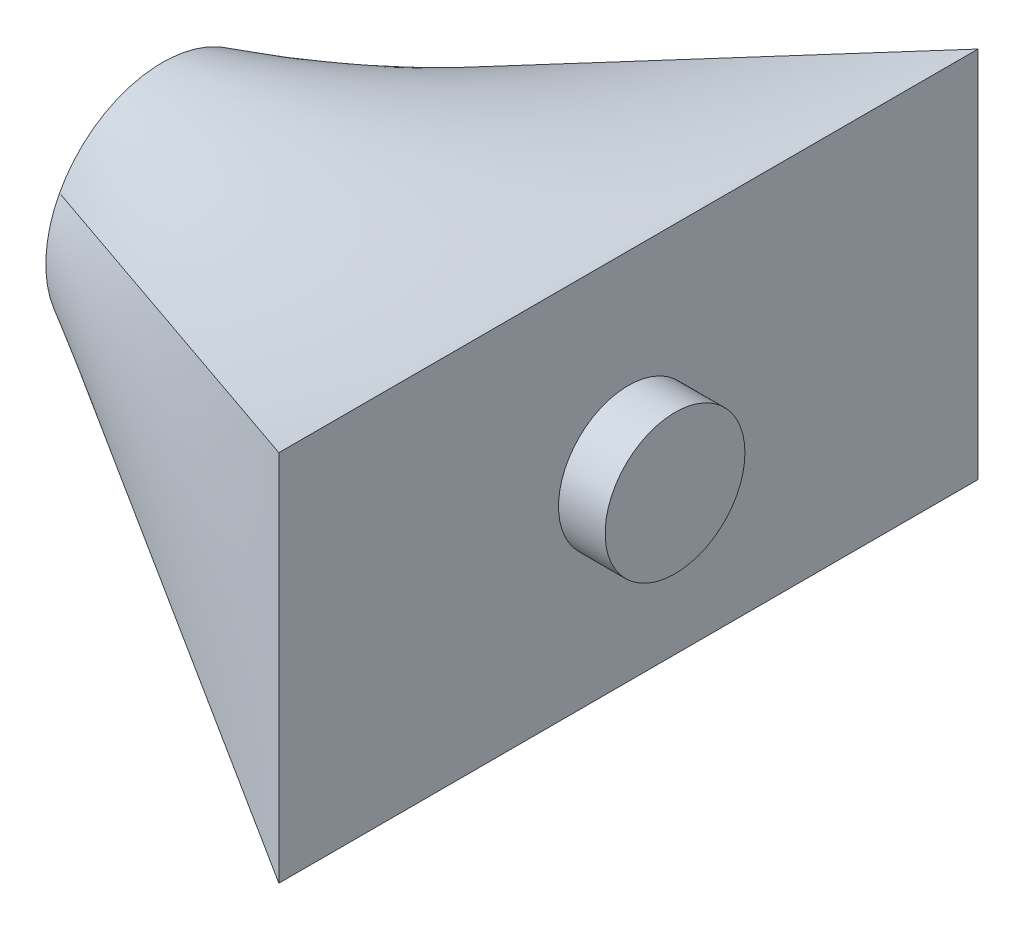
from build123d import *

# Parameters (mm, degrees)
SKETCH2_W           = 150
SKETCH2_H           = 80
SKETCH3_R           = 15
BOSS_EXTRUDE1_DEPTH = 10


with BuildPart() as part:
    # Sketch2 → Loft1 section 0
    with BuildSketch(Plane(origin=(100, 0, 0), x_dir=(0, 0, -1), z_dir=(1, 0, 0))):
        Rectangle(SKETCH2_W, SKETCH2_H)
    # Sketch1 for Loft1 → Loft1 section 1
    with BuildSketch(Plane(origin=(0, 0, 0), x_dir=(0, 0, -1), z_dir=(1, 0, 0))):
        with BuildLine():
            # circular arc as an exact rational Bezier (weights 1, cos(half-angle), 1)
            Bezier((-22.058823529, 11.764705882), (0, 53.125000003), (22.058823529, 11.764705882), weights=[1, 0.470588235, 1])
            Bezier((22.058823529, 11.764705882), (28.333333334, 0), (22.058823529, -11.764705882), weights=[1, 0.882352941, 1])
            Bezier((22.058823529, -11.764705882), (0, -53.125000003), (-22.058823529, -11.764705882), weights=[1, 0.470588235, 1])
            Bezier((-22.058823529, -11.764705882), (-28.333333334, 0), (-22.058823529, 11.764705882), weights=[1, 0.882352941, 1])
        make_face()
    loft()

    # Sketch3 → Boss-Extrude1 (add)
    with BuildSketch(Plane(origin=(100, 0, 0), x_dir=(0, 0, -1), z_dir=(1, 0, 0))):
        Circle(SKETCH3_R)
    extrude(amount=BOSS_EXTRUDE1_DEPTH)


solid = part.part
